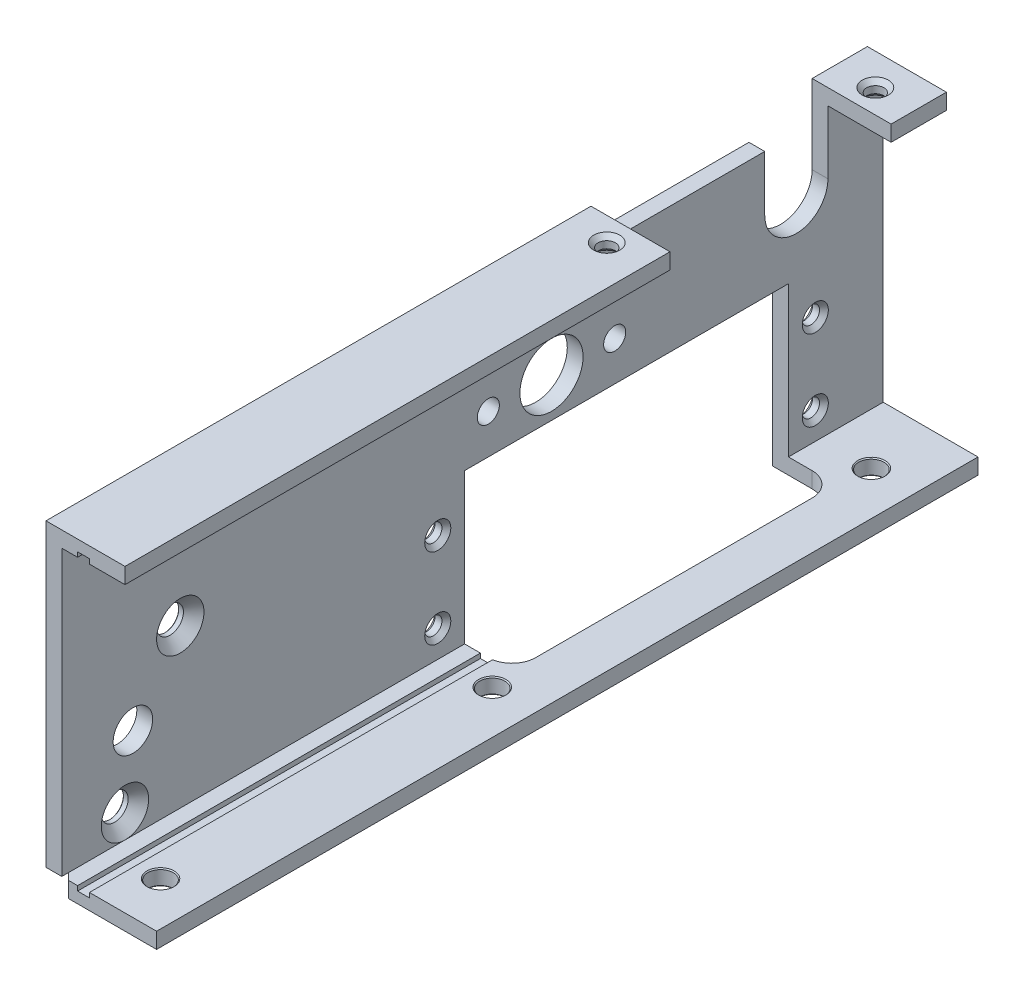
from build123d import *

# Parameters (mm, degrees)
EXTRUDE_1_DEPTH               = 104
SKETCH_2_W                    = 6
SKETCH_2_H                    = 104
CUT_EXTRUDE_1_DEPTH           = 21
HOLE_WIZARD_4_4_40_AT_2_COUNT = 2
HOLE_WIZARD_4_4_40_AT_2_PITCH = 10.2
HOLE_WIZARD_4_4_40_AT_3_COUNT = 2
HOLE_WIZARD_4_4_40_AT_3_PITCH = 48.876170063
HOLE_WIZARD_4_4_40_AT_4_COUNT = 2
HOLE_WIZARD_4_4_40_AT_4_PITCH = 47.8
HOLE_WIZARD_4_4_40_AT_5_COUNT = 2
HOLE_WIZARD_4_4_40_AT_5_PITCH = 24.438085031
SKETCH_6_W                    = 10
SKETCH_6_H                    = 28
CUT_EXTRUDE_3_DEPTH           = 3
HOLE_WIZARD_M31_AT_2_COUNT    = 2
HOLE_WIZARD_M31_AT_2_PITCH    = 42
HOLE_WIZARD_M31_AT_3_COUNT    = 2
HOLE_WIZARD_M31_AT_3_PITCH    = 90
HOLE_WIZARD_2_4_40_AT_2_COUNT = 2
HOLE_WIZARD_2_4_40_AT_2_PITCH = 34
SKETCH_13_W                   = 1.5
SKETCH_13_H                   = 37.2
CUT_EXTRUDE_6_DEPTH           = 54
HOLE_WIZARD_3_AT_2_COUNT      = 2
HOLE_WIZARD_3_AT_2_PITCH      = 12
HOLE_WIZARD_3_AT_3_COUNT      = 2
HOLE_WIZARD_3_AT_3_PITCH      = 7.071067812
HOLE_WIZARD_3_AT_4_COUNT      = 2
HOLE_WIZARD_3_AT_4_PITCH      = 29.83286778
CUT_EXTRUDE_8_DEPTH           = 2
SKETCH_18_R                   = 4
SKETCH_18_R_2                 = 1.4
CUT_EXTRUDE_9_DEPTH           = 3
CUT_EXTRUDE_10_REACH          = 4
SKETCH_19_R                   = 2.5


with BuildPart() as part:
    # Эскиз1 → Бобышка-Вытянуть1 (new body)
    with BuildSketch(Plane.XY):
        Polygon((0, 40), (0, 0), (20, 0), (20, 2), (2, 2), (2, 38), (10, 38), (10, 40), align=None)
    extrude(amount=EXTRUDE_1_DEPTH)

    # Эскиз2 → Вырез-Вытянуть1 (cut)
    with BuildSketch(Plane.XZ):
        with BuildLine():
            Line((5, 53), (0, 53))
            Line((0, 53), (0, 12))
            Line((0, 12), (5, 12))
            ThreePointArc((5, 12), (7.121320344, 12.878679656), (8, 15))
            Line((8, 15), (8, 50))
            ThreePointArc((8, 50), (7.121320344, 52.121320344), (5, 53))
        make_face()
        with Locations((17, 52)):
            Rectangle(SKETCH_2_W, SKETCH_2_H)
    extrude(amount=-CUT_EXTRUDE_1_DEPTH, mode=Mode.SUBTRACT)

    # Эскиз3 → 4_отв_4-40 (revolve, cut)
    with BuildSketch(Plane(origin=(0, 15.6, 8.6), x_dir=(0, 0, 1), z_dir=(0, 1, 0))):
        Polygon((0, 0), (0, 2), (1.651, 2), (1.0922, 1.4412), (1.0922, 0.5588), (1.651, 0), align=None)
    hole_wizard_4_4_40 = revolve(axis=Axis((-6.35, 15.6, 8.6), (1, 0, 0)), mode=Mode.SUBTRACT)

    # 4_отв_4-40 at 2: 4_отв_4-40 ×2
    with Locations(*[(0, -i * HOLE_WIZARD_4_4_40_AT_2_PITCH, 0) for i in range(1, HOLE_WIZARD_4_4_40_AT_2_COUNT)]):
        add(hole_wizard_4_4_40, mode=Mode.SUBTRACT)

    # 4_отв_4-40 at 3: 4_отв_4-40 ×2
    with Locations(*[Vector(0, -0.208690656, 0.977981702) * (i * HOLE_WIZARD_4_4_40_AT_3_PITCH) for i in range(1, HOLE_WIZARD_4_4_40_AT_3_COUNT)]):
        add(hole_wizard_4_4_40, mode=Mode.SUBTRACT)

    # 4_отв_4-40 at 4: 4_отв_4-40 ×2
    with Locations(*[(0, 0, i * HOLE_WIZARD_4_4_40_AT_4_PITCH) for i in range(1, HOLE_WIZARD_4_4_40_AT_4_COUNT)]):
        add(hole_wizard_4_4_40, mode=Mode.SUBTRACT)

    # 4_отв_4-40 at 5: 4_отв_4-40 ×2
    with Locations(*[Vector(0, -0.208690656, 0.977981702) * (i * HOLE_WIZARD_4_4_40_AT_5_PITCH) for i in range(1, HOLE_WIZARD_4_4_40_AT_5_COUNT)]):
        add(hole_wizard_4_4_40, mode=Mode.SUBTRACT)

    # Эскиз6 → Вырез-Вытянуть3 (cut)
    with BuildSketch(Plane(origin=(0, 40, 0), x_dir=(1, 0, 0), z_dir=(0, 1, 0))):
        with Locations((5, -21)):
            Rectangle(SKETCH_6_W, SKETCH_6_H)
    extrude(amount=-CUT_EXTRUDE_3_DEPTH, mode=Mode.SUBTRACT)

    # Эскиз8 → Отверстие с зазором M31 (revolve, cut)
    with BuildSketch(Plane(origin=(8.5, 0, 98), x_dir=(0, 0, -1), z_dir=(1, 0, 0))):
        Polygon((0, 0), (0, 2), (1.725, 2), (1.6, 1.875), (1.6, 0.125), (1.725, 0), align=None)
    hole_wizard_m31 = revolve(axis=Axis((8.5, -6.35, 98), (0, 1, 0)), mode=Mode.SUBTRACT)

    # Отверстие с зазором M31 at 2: Отверстие с зазором M31 ×2
    with Locations(*[(0, 0, -i * HOLE_WIZARD_M31_AT_2_PITCH) for i in range(1, HOLE_WIZARD_M31_AT_2_COUNT)]):
        add(hole_wizard_m31, mode=Mode.SUBTRACT)

    # Отверстие с зазором M31 at 3: Отверстие с зазором M31 ×2
    with Locations(*[(0, 0, -i * HOLE_WIZARD_M31_AT_3_PITCH) for i in range(1, HOLE_WIZARD_M31_AT_3_COUNT)]):
        add(hole_wizard_m31, mode=Mode.SUBTRACT)

    # Эскиз11 → 2_отв_4-40 (revolve, cut)
    with BuildSketch(Plane(origin=(5, 40, 38), x_dir=(0, 0, 1), z_dir=(1, 0, 0))):
        Polygon((0, 0), (0, 2), (1.651, 2), (1.0922, 1.4412), (1.0922, 0.5588), (1.651, 0), align=None)
    hole_wizard_2_4_40 = revolve(axis=Axis((5, 46.35, 38), (0, -1, 0)), mode=Mode.SUBTRACT)

    # 2_отв_4-40 at 2: 2_отв_4-40 ×2
    with Locations(*[(0, 0, -i * HOLE_WIZARD_2_4_40_AT_2_PITCH) for i in range(1, HOLE_WIZARD_2_4_40_AT_2_COUNT)]):
        add(hole_wizard_2_4_40, mode=Mode.SUBTRACT)

    # Эскиз13 → Вырез-Вытянуть6 (cut)
    with BuildSketch(Plane.XY.offset(104)):
        with Locations((4.75, 20)):
            Rectangle(SKETCH_13_W, SKETCH_13_H)
    extrude(amount=-CUT_EXTRUDE_6_DEPTH, mode=Mode.SUBTRACT)

    # Эскиз15 → М3 потай (revolve, cut)
    with BuildSketch(Plane(origin=(2, 34, 89), x_dir=(0, 0, -1), z_dir=(0, 1, 0))):
        Polygon((0, 0), (0, 2), (1.8, 2), (1.7, 1.9), (1.7, 1.3), (3, 0), align=None)
    hole_wizard_3 = revolve(axis=Axis((8.35, 34, 89), (-1, 0, 0)), mode=Mode.SUBTRACT)

    # М3 потай at 2: М3 потай ×2
    with Locations(*[(0, -i * HOLE_WIZARD_3_AT_2_PITCH, 0) for i in range(1, HOLE_WIZARD_3_AT_2_COUNT)]):
        add(hole_wizard_3, mode=Mode.SUBTRACT)

    # М3 потай at 3: М3 потай ×2
    with Locations(*[Vector(0, 0.141421356, 0.989949494) * (i * HOLE_WIZARD_3_AT_3_PITCH) for i in range(1, HOLE_WIZARD_3_AT_3_COUNT)]):
        add(hole_wizard_3, mode=Mode.SUBTRACT)

    # М3 потай at 4: М3 потай ×2
    with Locations(*[Vector(0, -0.972082209, 0.234640533) * (i * HOLE_WIZARD_3_AT_4_PITCH) for i in range(1, HOLE_WIZARD_3_AT_4_COUNT)]):
        add(hole_wizard_3, mode=Mode.SUBTRACT)

    # Эскиз17 → Вырез-Вытянуть8 (cut)
    with BuildSketch(Plane.XZ):
        Polygon((0, 104), (2.828427125, 104), (0, 101.171572875), align=None)
    extrude(amount=-CUT_EXTRUDE_8_DEPTH, mode=Mode.SUBTRACT)

    # Эскиз18 → Вырез-Вытянуть9 (cut, through all)
    with BuildSketch(Plane(origin=(2, 0, 0), x_dir=(0, 0, -1), z_dir=(1, 0, 0))):
        with BuildLine():
            Line((-7, 30), (-7, 37))
            Line((-7, 37), (-15, 37))
            Line((-15, 37), (-15, 30))
            ThreePointArc((-15, 30), (-11, 26), (-7, 30))
        make_face()
        with Locations((-42, 26)):
            Circle(SKETCH_18_R)
        with Locations((-50, 26)):
            Circle(SKETCH_18_R_2)
        with Locations((-34, 26)):
            Circle(SKETCH_18_R_2)
    extrude(amount=-CUT_EXTRUDE_9_DEPTH, mode=Mode.SUBTRACT)

    # Эскиз19 → Вырез-Вытянуть10 (cut, up to next)
    with BuildSketch(Plane(origin=(2, 0, 0), x_dir=(0, 0, -1), z_dir=(1, 0, 0)), mode=Mode.PRIVATE) as cut_extrude_10_sk1:
        with Locations((-95, 13.5)):
            Circle(SKETCH_19_R)
    cut_extrude_10_tool1 = extrude(cut_extrude_10_sk1.sketch, amount=-CUT_EXTRUDE_10_REACH, mode=Mode.PRIVATE) & part.part
    add(cut_extrude_10_tool1.solids().sort_by_distance((2, 13.5, 95))[0], mode=Mode.SUBTRACT)


solid = part.part
